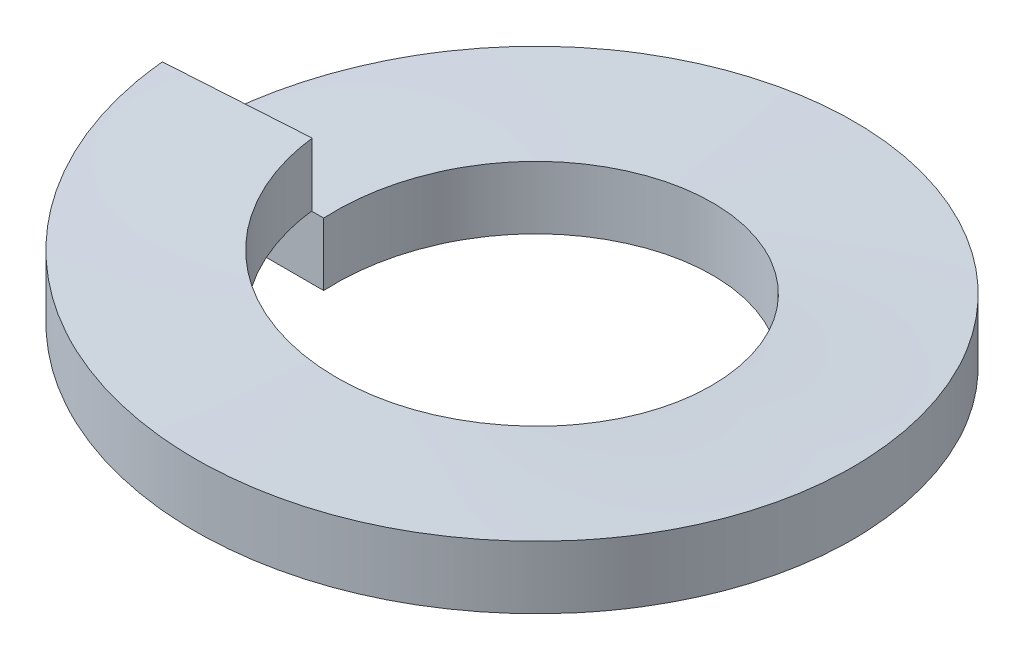
from build123d import *

# Parameters (mm, degrees)
SWEEP1_PITCH       = 0.615757576
SWEEP1_HEIGHT      = 0.6096
SWEEP1_RADIUS      = 2.667
SWEEP1_START_ANGLE = -90
SKETCH1_W          = 1.143
SKETCH1_H          = 0.508


with BuildPart() as part:
    # Sweep1: sweep along a helix
    with BuildLine() as sweep1_path:
        add(Helix(SWEEP1_PITCH, SWEEP1_HEIGHT, SWEEP1_RADIUS, center=(0, 0, 0), direction=(0, 1, 0), lefthand=True, mode=Mode.PRIVATE).rotate(Axis((0, 0, 0), (0, 1, 0)), SWEEP1_START_ANGLE))
    # Sketch1 → Sweep1 (sweep)
    with BuildSketch(Plane.XY):
        with Locations((-2.0955, 0.254)):
            Rectangle(SKETCH1_W, SKETCH1_H)
    sweep(path=sweep1_path.line, is_frenet=True)


solid = part.part
